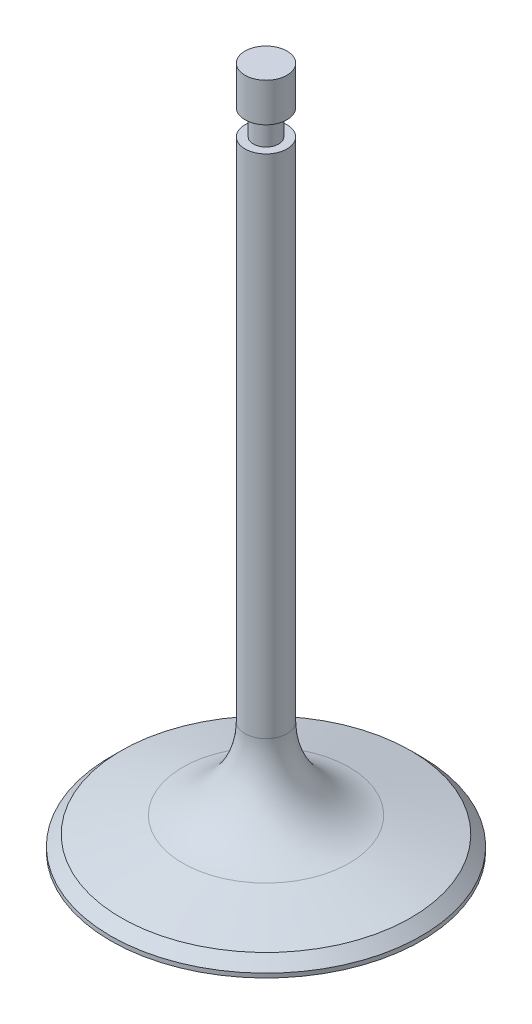
from build123d import *


with BuildPart() as part:
    # Sketch1 → Revolve1 (revolve)
    with BuildSketch(Plane(origin=(0, 0, 0), x_dir=(0, 0, -1), z_dir=(1, 0, 0))):
        with BuildLine():
            Line((0, 0), (0, 82.79))
            Line((0, 82.79), (2.5, 82.79))
            Line((2.5, 82.79), (2.5, 78.19))
            Line((2.5, 78.19), (1.5, 78.19))
            Line((1.5, 78.19), (1.5, 75.19))
            Line((1.5, 75.19), (2.5, 75.19))
            Line((2.5, 75.19), (2.5, 14.875520468))
            ThreePointArc((2.5, 14.875520468), (4.566466597, 8.787906178), (9.911809549, 5.216262205))
            Line((9.911809549, 5.216262205), (17.25, 3.25))
            Line((17.25, 3.25), (18.5, 2))
            Line((18.5, 2), (18.5, 1.5))
            ThreePointArc((18.5, 1.5), (9.280355597, 0.375614308), (0, 0))
        make_face()
    revolve(axis=Axis((0, 0, 0), (0, 1, 0)))


solid = part.part
